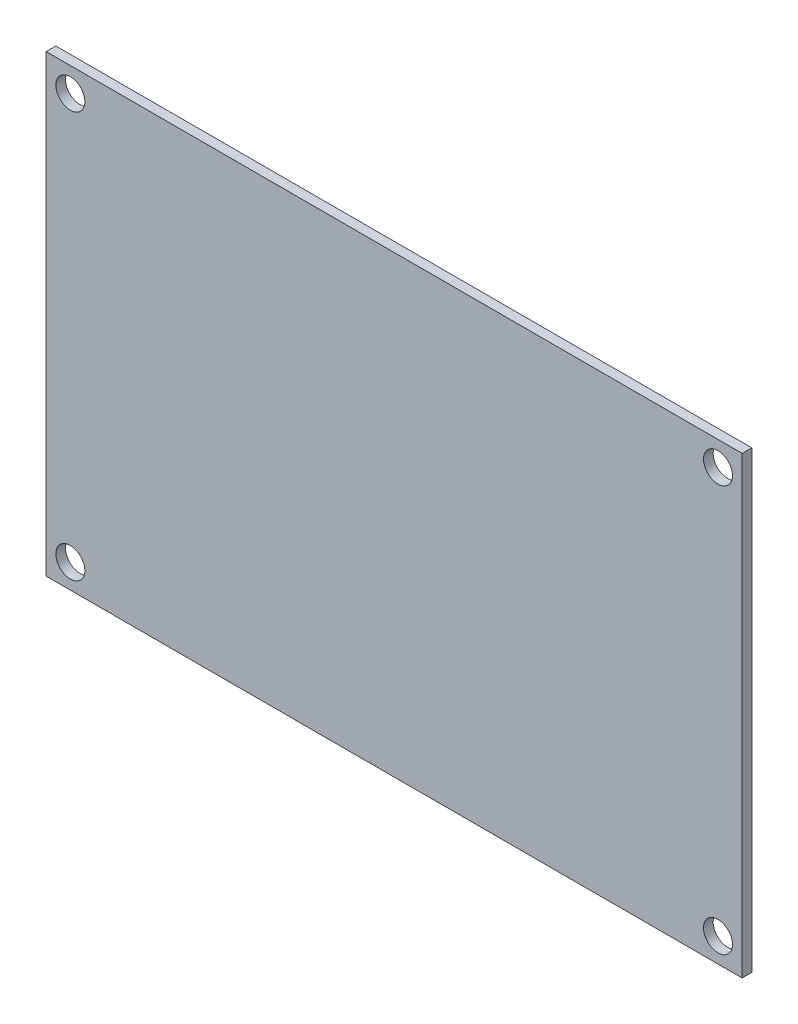
from build123d import *

# Parameters (mm, degrees)
SKETCH_1_W          = 72
SKETCH_1_H          = 47
EXTRUDE_1_DEPTH     = 1
SKETCH_2_R          = 1.5
CUT_EXTRUDE_1_DEPTH = 2


with BuildPart() as part:
    # ｽｹｯﾁ1 → ﾎﾞｽ - 押し出し1 (new body)
    with BuildSketch(Plane.XY):
        with Locations((-36, 23.5)):
            Rectangle(SKETCH_1_W, SKETCH_1_H)
    extrude(amount=EXTRUDE_1_DEPTH)

    # ｽｹｯﾁ2 → ｶｯﾄ - 押し出し1 (cut, through all)
    with BuildSketch(Plane.XY.offset(1)):
        with Locations((-69.5, 44.5)):
            Circle(SKETCH_2_R)
        with Locations((-69.5, 2.5)):
            Circle(SKETCH_2_R)
        with Locations((-2.5, 44.5)):
            Circle(SKETCH_2_R)
        with Locations((-2.5, 2.5)):
            Circle(SKETCH_2_R)
    extrude(amount=-CUT_EXTRUDE_1_DEPTH, mode=Mode.SUBTRACT)


solid = part.part
